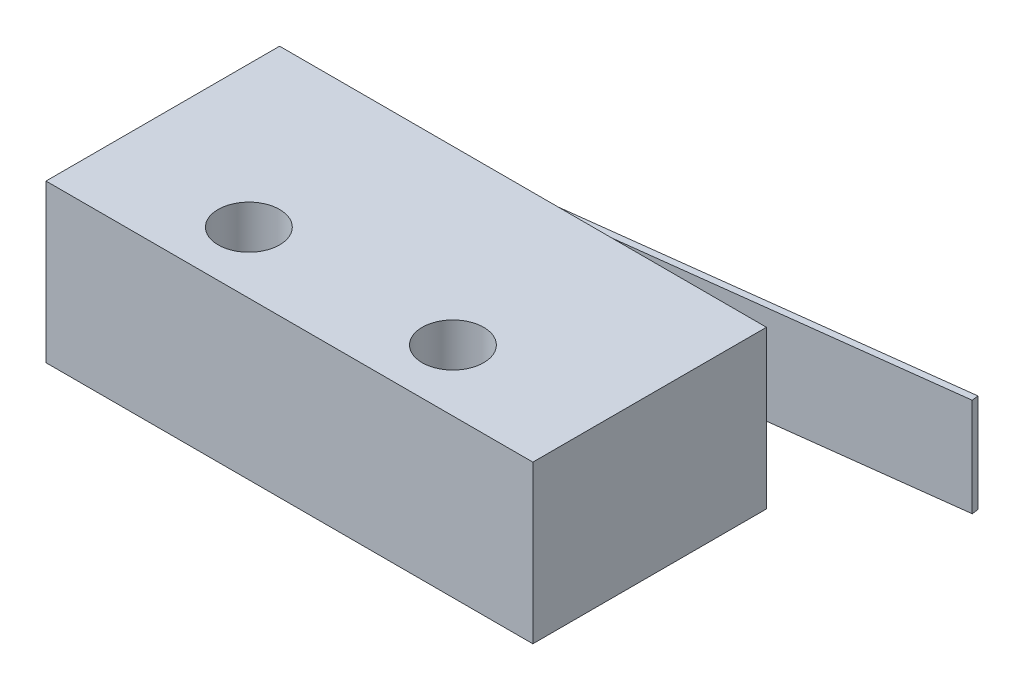
from build123d import *

# Parameters (mm, degrees)
SKETCH_1_W          = 19.8
SKETCH_1_H          = 9.5
EXTRUDE_1_DEPTH     = 6.4
SKETCH_2_R          = 1.25
CUT_EXTRUDE_1_DEPTH = 6.4
EXTRUDE_START       = -1.2
EXTRUDE_2_DEPTH     = 4


with BuildPart() as part:
    # 草圖1 → 填料-伸長1 (new body)
    with BuildSketch(Plane(origin=(0, 0, 0), x_dir=(1, 0, 0), z_dir=(0, 1, 0))):
        with Locations((9.9, 4.75)):
            Rectangle(SKETCH_1_W, SKETCH_1_H)
    extrude(amount=EXTRUDE_1_DEPTH)

    # 草圖2 → 除料-伸長1 (cut)
    with BuildSketch(Plane(origin=(0, 6.4, 0), x_dir=(1, 0, 0), z_dir=(0, 1, 0))):
        with Locations((5.75, 2.5)):
            Circle(SKETCH_2_R)
        with Locations((14.05, 2.5)):
            Circle(SKETCH_2_R)
    extrude(amount=-CUT_EXTRUDE_1_DEPTH, mode=Mode.SUBTRACT)


with BuildPart() as body_2:
    # 草圖3 → 填料-伸長2 (new body)
    with BuildSketch(Plane(origin=(0, 6.4, 0), x_dir=(1, 0, 0), z_dir=(0, 1, 0)).offset(EXTRUDE_START)):
        Polygon((2.644966483, 9.5), (25.353811231, 12.314699581), (25.320517467, 12.583311873), (2.61167272, 9.768612292), align=None)
    extrude(amount=-EXTRUDE_2_DEPTH)


solid = Compound([part.part, body_2.part])
